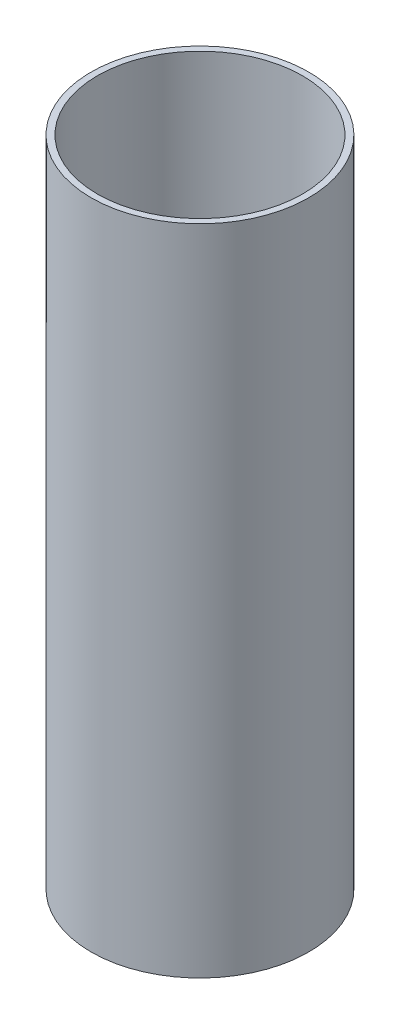
from build123d import *

# Parameters (mm, degrees)
SKETCH1_R   = 6.35
SKETCH1_R_2 = 5.98076085


with BuildPart() as part:
    # Sweep1: sweep along a path in Sketch2
    with BuildLine(Plane(origin=(0, 0, 0), x_dir=(0, 0, -1), z_dir=(1, 0, 0))) as sweep1_path:
        Line((0, 0), (0, -38.1))
    # Sketch1 → Sweep1 (sweep)
    with BuildSketch(Plane(origin=(0, 0, 0), x_dir=(1, 0, 0), z_dir=(0, 1, 0))):
        Circle(SKETCH1_R)
        Circle(SKETCH1_R_2, mode=Mode.SUBTRACT)
    sweep(path=sweep1_path.line)


solid = part.part
